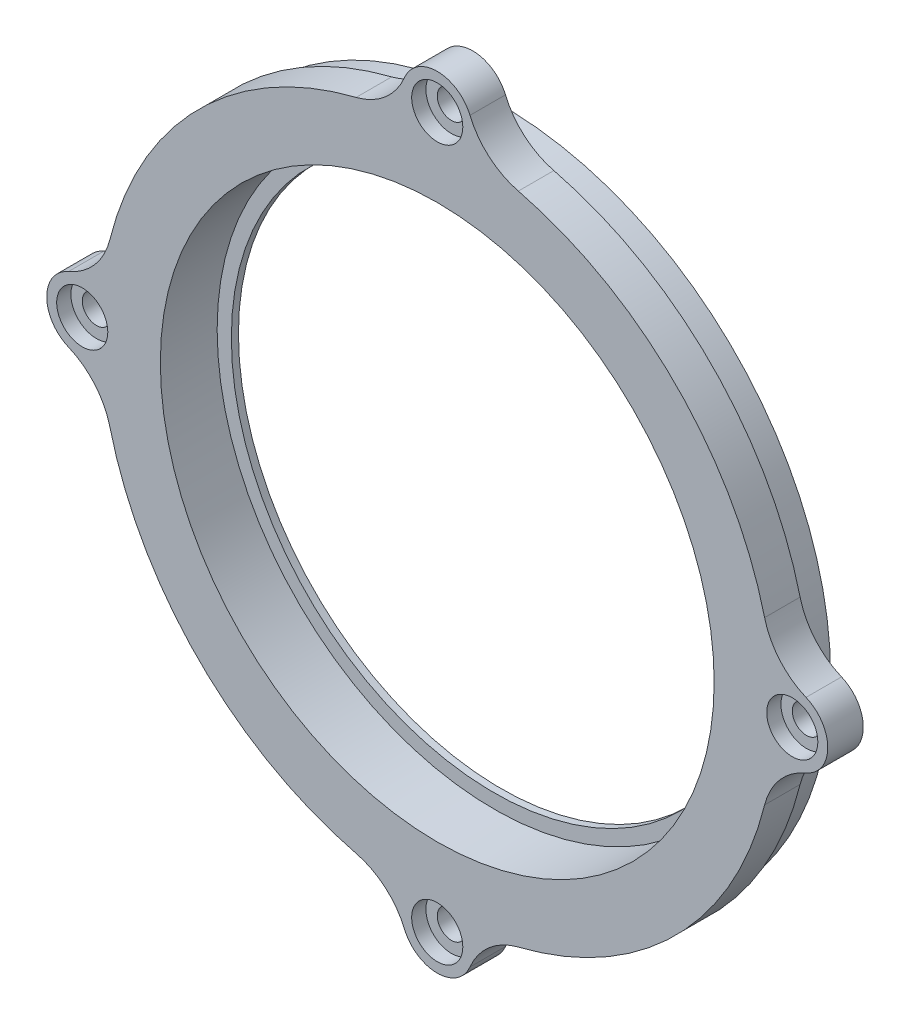
from build123d import *

# Parameters (mm, degrees)
SKETCH2_R           = 50
SKETCH2_R_2         = 39
BOSS_EXTRUDE1_DEPTH = 5
SKETCH3_R           = 47
SKETCH3_R_2         = 3
SKETCH3_R_3         = 39
BOSS_EXTRUDE2_DEPTH = 4
SKETCH4_R           = 39
SKETCH4_R_2         = 37
BOSS_EXTRUDE3_DEPTH = 1
SKETCH6_R           = 5
SKETCH6_R_2         = 2
BOSS_EXTRUDE4_DEPTH = 5
FILLET1_R           = 5
SKETCH7_R           = 3.6
CUT_EXTRUDE1_DEPTH  = 3
SKETCH8_R           = 3.15
CUT_EXTRUDE2_DEPTH  = 4
SKETCH9_R           = 3.15
CUT_EXTRUDE3_DEPTH  = 6.6
SKETCH10_R          = 57.5
SKETCH10_R_2        = 47.5
CUT_EXTRUDE4_DEPTH  = 5
SKETCH11_R          = 47.5
SKETCH11_R_2        = 46.4
CUT_EXTRUDE5_DEPTH  = 4
SKETCH12_R          = 2
BOSS_EXTRUDE7_DEPTH = 5
FILLET3_R           = 10
SKETCH14_R          = 3.6
CUT_EXTRUDE8_DEPTH  = 2


with BuildPart() as part:
    # Sketch2 → Boss-Extrude1 (new body)
    with BuildSketch(Plane.XY):
        Circle(SKETCH2_R)
        Circle(SKETCH2_R_2, mode=Mode.SUBTRACT)
    extrude(amount=BOSS_EXTRUDE1_DEPTH)

    # Sketch3 → Boss-Extrude2 (add)
    with BuildSketch(Plane(origin=(0, 0, 0), x_dir=(-1, 0, 0), z_dir=(0, 0, -1))):
        Circle(SKETCH3_R)
        with Locations((-43, 0)):
            Circle(SKETCH3_R_2, mode=Mode.SUBTRACT)
        Circle(SKETCH3_R_3, mode=Mode.SUBTRACT)
        with Locations((-32.939911054, 27.639867217)):
            Circle(SKETCH3_R_2, mode=Mode.SUBTRACT)
        with Locations((-7.46687164, 42.34673338)):
            Circle(SKETCH3_R_2, mode=Mode.SUBTRACT)
        with Locations((21.5, 37.239092363)):
            Circle(SKETCH3_R_2, mode=Mode.SUBTRACT)
        with Locations((40.406782694, 14.706866163)):
            Circle(SKETCH3_R_2, mode=Mode.SUBTRACT)
        with Locations((40.406782694, -14.706866163)):
            Circle(SKETCH3_R_2, mode=Mode.SUBTRACT)
        with Locations((21.5, -37.239092363)):
            Circle(SKETCH3_R_2, mode=Mode.SUBTRACT)
        with Locations((-7.46687164, -42.34673338)):
            Circle(SKETCH3_R_2, mode=Mode.SUBTRACT)
        with Locations((-32.939911054, -27.639867217)):
            Circle(SKETCH3_R_2, mode=Mode.SUBTRACT)
    extrude(amount=BOSS_EXTRUDE2_DEPTH)

    # Sketch4 → Boss-Extrude3 (add)
    with BuildSketch(Plane(origin=(0, 0, -4), x_dir=(-1, 0, 0), z_dir=(0, 0, -1))):
        Circle(SKETCH4_R)
        Circle(SKETCH4_R_2, mode=Mode.SUBTRACT)
    extrude(amount=-BOSS_EXTRUDE3_DEPTH)

    # Sketch6 → Boss-Extrude4 (add)
    with BuildSketch(Plane.XY.offset(5)):
        with Locations((52, 0)):
            Circle(SKETCH6_R)
        with Locations((52, 0)):
            Circle(SKETCH6_R_2, mode=Mode.SUBTRACT)
        with Locations((-52, 0)):
            Circle(SKETCH6_R)
        with Locations((-52, 0)):
            Circle(SKETCH6_R_2, mode=Mode.SUBTRACT)
        with Locations((0, 52)):
            Circle(SKETCH6_R)
        with Locations((0, 52)):
            Circle(SKETCH6_R_2, mode=Mode.SUBTRACT)
        with Locations((0, -52)):
            Circle(SKETCH6_R)
        with Locations((0, -52)):
            Circle(SKETCH6_R_2, mode=Mode.SUBTRACT)
    extrude(amount=-BOSS_EXTRUDE4_DEPTH)

    # Fillet1
    fillet1_edges = [part.edges().sort_by_distance(p)[0] for p in [
        (49.798076923, -4.489046086, 2.5),
        (49.798076923, 4.489046086, 2.5),
        (-49.798076923, 4.489046086, 2.5),
        (-49.798076923, -4.489046086, 2.5),
        (4.489046086, 49.798076923, 2.5),
        (-4.489046086, 49.798076923, 2.5),
        (-4.489046086, -49.798076923, 2.5),
        (4.489046086, -49.798076923, 2.5),
    ]]
    fillet(fillet1_edges, radius=FILLET1_R)

    # Sketch7 → Cut-Extrude1 (cut)
    with BuildSketch(Plane.XY.offset(5)):
        with Locations((52, 0)):
            Circle(SKETCH7_R)
        with Locations((0, 52)):
            Circle(SKETCH7_R)
        with Locations((-52, 0)):
            Circle(SKETCH7_R)
        with Locations((0, -52)):
            Circle(SKETCH7_R)
    extrude(amount=-CUT_EXTRUDE1_DEPTH, mode=Mode.SUBTRACT)

    # Sketch8 → Cut-Extrude2 (cut)
    with BuildSketch(Plane(origin=(0, 0, -4), x_dir=(-1, 0, 0), z_dir=(0, 0, -1))):
        with Locations((-32.939911054, 27.639867217)):
            Circle(SKETCH8_R)
        with Locations((-43, 0)):
            Circle(SKETCH8_R)
        with Locations((-7.46687164, 42.34673338)):
            Circle(SKETCH8_R)
        with Locations((21.5, 37.239092363)):
            Circle(SKETCH8_R)
        with Locations((40.406782694, 14.706866163)):
            Circle(SKETCH8_R)
        with Locations((40.406782694, -14.706866163)):
            Circle(SKETCH8_R)
        with Locations((21.5, -37.239092363)):
            Circle(SKETCH8_R)
        with Locations((-7.46687164, -42.34673338)):
            Circle(SKETCH8_R)
        with Locations((-32.939911054, -27.639867217)):
            Circle(SKETCH8_R)
    extrude(amount=-CUT_EXTRUDE2_DEPTH, mode=Mode.SUBTRACT)

    # Sketch9 → Cut-Extrude3 (cut)
    with BuildSketch(Plane(origin=(0, 0, -4), x_dir=(-1, 0, 0), z_dir=(0, 0, -1))):
        with Locations((-43, 0)):
            Circle(SKETCH9_R)
        with Locations((-32.939911054, 27.639867217)):
            Circle(SKETCH9_R)
        with Locations((-7.46687164, 42.34673338)):
            Circle(SKETCH9_R)
        with Locations((21.5, 37.239092363)):
            Circle(SKETCH9_R)
        with Locations((40.406782694, 14.706866163)):
            Circle(SKETCH9_R)
        with Locations((40.406782694, -14.706866163)):
            Circle(SKETCH9_R)
        with Locations((21.5, -37.239092363)):
            Circle(SKETCH9_R)
        with Locations((-7.46687164, -42.34673338)):
            Circle(SKETCH9_R)
        with Locations((-32.939911054, -27.639867217)):
            Circle(SKETCH9_R)
    extrude(amount=-CUT_EXTRUDE3_DEPTH, mode=Mode.SUBTRACT)

    # Sketch10 → Cut-Extrude4 (cut)
    with BuildSketch(Plane(origin=(0, 0, 0), x_dir=(-1, 0, 0), z_dir=(0, 0, -1))):
        Circle(SKETCH10_R)
        Circle(SKETCH10_R_2, mode=Mode.SUBTRACT)
    extrude(amount=-CUT_EXTRUDE4_DEPTH, mode=Mode.SUBTRACT)

    # Sketch11 → Cut-Extrude5 (cut)
    with BuildSketch(Plane(origin=(0, 0, -4), x_dir=(-1, 0, 0), z_dir=(0, 0, -1))):
        Circle(SKETCH11_R)
        Circle(SKETCH11_R_2, mode=Mode.SUBTRACT)
    extrude(amount=-CUT_EXTRUDE5_DEPTH, mode=Mode.SUBTRACT)

    # Sketch12 → Boss-Extrude7 (add)
    with BuildSketch(Plane.XY.offset(5)):
        with BuildLine():
            ThreePointArc((47.3125, -4.216318744), (55, 0), (47.3125, 4.216318744))
            ThreePointArc((47.3125, 4.216318744), (47.5, 0), (47.3125, -4.216318744))
        make_face()
        with Locations((50, 0)):
            Circle(SKETCH12_R, mode=Mode.SUBTRACT)
        with BuildLine():
            ThreePointArc((-4.216318744, 47.3125), (0, 47.5), (4.216318744, 47.3125))
            ThreePointArc((4.216318744, 47.3125), (0, 55), (-4.216318744, 47.3125))
        make_face()
        with Locations((0, 50)):
            Circle(SKETCH12_R, mode=Mode.SUBTRACT)
        with BuildLine():
            ThreePointArc((-4.216318744, -47.3125), (0, -55), (4.216318744, -47.3125))
            ThreePointArc((4.216318744, -47.3125), (0, -47.5), (-4.216318744, -47.3125))
        make_face()
        with Locations((0, -50)):
            Circle(SKETCH12_R, mode=Mode.SUBTRACT)
        with BuildLine():
            ThreePointArc((-47.3125, -4.216318744), (-47.5, 0), (-47.3125, 4.216318744))
            ThreePointArc((-47.3125, 4.216318744), (-55, 0), (-47.3125, -4.216318744))
        make_face()
        with Locations((-50, 0)):
            Circle(SKETCH12_R, mode=Mode.SUBTRACT)
    extrude(amount=-BOSS_EXTRUDE7_DEPTH)

    # Fillet3
    fillet3_edges = [part.edges().sort_by_distance(p)[0] for p in [
        (47.3125, -4.216318744, 2.5),
        (47.3125, 4.216318744, 2.5),
        (4.216318744, 47.3125, 2.5),
        (-4.216318744, 47.3125, 2.5),
        (-47.3125, 4.216318744, 2.5),
        (-47.3125, -4.216318744, 2.5),
        (-4.216318744, -47.3125, 2.5),
        (4.216318744, -47.3125, 2.5),
    ]]
    fillet(fillet3_edges, radius=FILLET3_R)

    # Sketch14 → Cut-Extrude8 (cut)
    with BuildSketch(Plane.XY.offset(5)):
        with Locations((50, 0)):
            Circle(SKETCH14_R)
        with Locations((0, -50)):
            Circle(SKETCH14_R)
        with Locations((-50, 0)):
            Circle(SKETCH14_R)
        with Locations((0, 50)):
            Circle(SKETCH14_R)
    extrude(amount=-CUT_EXTRUDE8_DEPTH, mode=Mode.SUBTRACT)


solid = part.part
